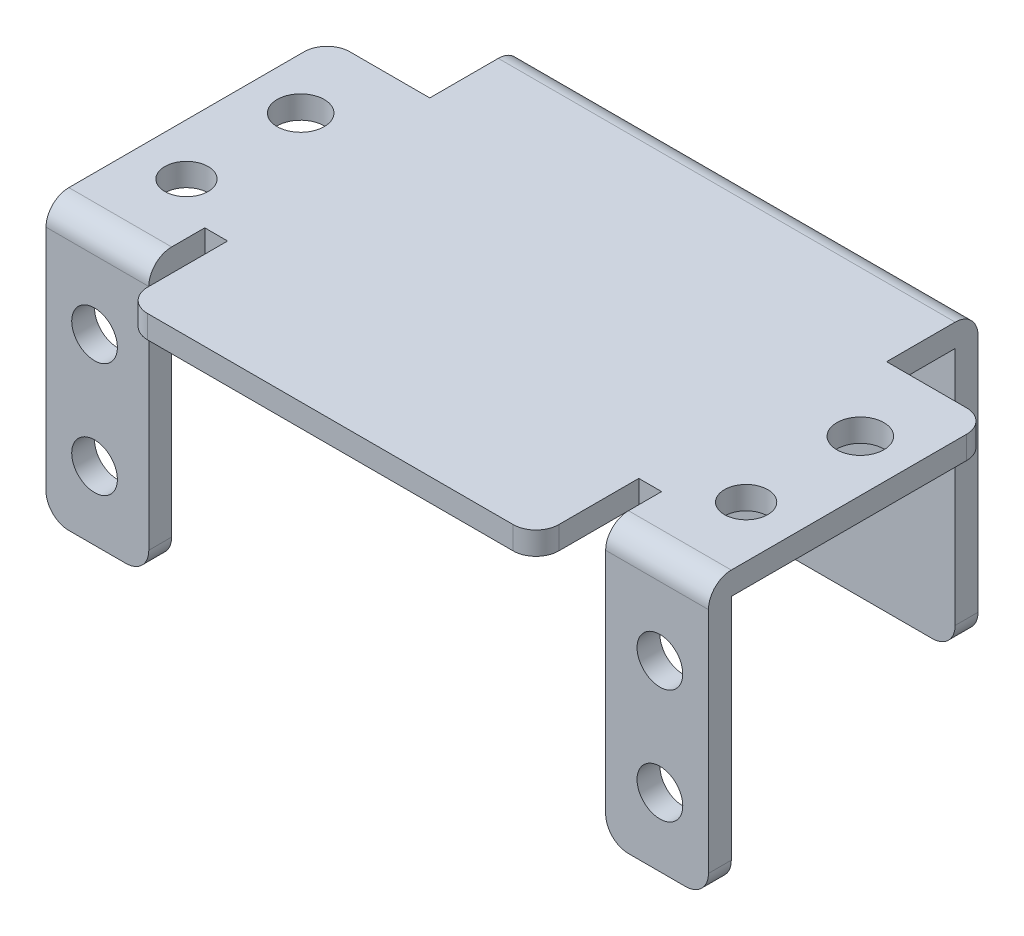
from build123d import *

# Parameters (mm, degrees)
SKETCH_1_W            = 32.6
SKETCH_1_H            = 23.999999657
EXTRUDE_1_DEPTH       = 8.999999702
SKETCH_2_W            = 30.6
SKETCH_2_H            = 22
CUT_EXTRUDE_1_DEPTH   = 9.999999702
SKETCH_3_W            = 27.7
SKETCH_3_H            = 1.999999657
EXTRUDE_2_DEPTH       = 49.000000298
SKETCH_4_W            = 8.999999702
SKETCH_4_H            = 1.999999657
EXTRUDE_3_DEPTH       = 4.9
SKETCH_5_W            = 8.999999702
SKETCH_5_H            = 2
EXTRUDE_4_DEPTH       = 22
SKETCH_6_W            = 9
SKETCH_6_H            = 8
CUT_EXTRUDE_2_DEPTH   = 24.999999657
SKETCH_7_W            = 9
SKETCH_7_H            = 8
CUT_EXTRUDE_3_DEPTH   = 24.999999657
SKETCH_8_W            = 40
SKETCH_8_H            = 2
EXTRUDE_5_DEPTH       = 23.000000343
SKETCH_9_W            = 36.000000596
SKETCH_9_H            = 1.999999657
EXTRUDE_6_DEPTH       = 9
HOLE_WIZARD_4_0_4_1_D = 4
FILLET_1_R            = 2
SKETCH_12_R           = 1.897672249
SKETCH_12_R_2         = 2.0621459
CUT_EXTRUDE_4_DEPTH   = 2.999999657


with BuildPart() as part:
    # 草图1 → 凸台-拉伸1 (new body)
    with BuildSketch(Plane(origin=(29, 0, 0), x_dir=(0, 0, -1), z_dir=(1, 0, 0))):
        with Locations((-16.3, 13.000000171)):
            Rectangle(SKETCH_1_W, SKETCH_1_H)
    extrude(amount=-EXTRUDE_1_DEPTH)

    # 草图2 → 切除-拉伸1 (cut, through all)
    with BuildSketch(Plane.ZY.offset(-20.000000298)):
        with Locations((15.3, 12.000000343)):
            Rectangle(SKETCH_2_W, SKETCH_2_H)
    extrude(amount=-CUT_EXTRUDE_1_DEPTH, mode=Mode.SUBTRACT)

    # 草图3 → 凸台-拉伸2 (add)
    with BuildSketch(Plane.ZY.offset(-20.000000298)):
        with Locations((13.85, 24.000000171)):
            Rectangle(SKETCH_3_W, SKETCH_3_H)
    extrude(amount=EXTRUDE_2_DEPTH)

    # 草图4 → 凸台-拉伸3 (add)
    with BuildSketch(Plane.XY.offset(27.7)):
        with Locations((-24.500000149, 24.000000171)):
            Rectangle(SKETCH_4_W, SKETCH_4_H)
    extrude(amount=EXTRUDE_3_DEPTH)

    # 草图5 → 凸台-拉伸4 (add)
    with BuildSketch(Plane.XZ.offset(-23.000000343)):
        with Locations((-24.500000149, 31.6)):
            Rectangle(SKETCH_5_W, SKETCH_5_H)
    extrude(amount=EXTRUDE_4_DEPTH)

    # 草图6 → 切除-拉伸2 (cut, through all)
    with BuildSketch(Plane(origin=(0, 25, 0), x_dir=(-1, 0, 0), z_dir=(0, 1, 0))):
        with Locations((24.5, 4)):
            Rectangle(SKETCH_6_W, SKETCH_6_H)
    extrude(amount=-CUT_EXTRUDE_2_DEPTH, mode=Mode.SUBTRACT)

    # 草图7 → 切除-拉伸3 (cut, through all)
    with BuildSketch(Plane(origin=(0, 25, 0), x_dir=(-1, 0, 0), z_dir=(0, 1, 0))):
        with Locations((-24.5, 4)):
            Rectangle(SKETCH_7_W, SKETCH_7_H)
    extrude(amount=-CUT_EXTRUDE_3_DEPTH, mode=Mode.SUBTRACT)

    # 草图8 → 凸台-拉伸5 (add)
    with BuildSketch(Plane.XZ.offset(-23.000000343)):
        with Locations((0, 1)):
            Rectangle(SKETCH_8_W, SKETCH_8_H)
    extrude(amount=EXTRUDE_5_DEPTH)

    # 草图9 → 凸台-拉伸6 (add)
    with BuildSketch(Plane.XY.offset(27.7)):
        with Locations((0, 24.000000171)):
            Rectangle(SKETCH_9_W, SKETCH_9_H)
    extrude(amount=EXTRUDE_6_DEPTH)

    # Ø4.0 (4) 直径孔1 (through all)
    with Locations(Plane(origin=(0, 0, 30.6), x_dir=(-1, 0, 0), z_dir=(0, 0, -1))):
        with Locations((-24.75, 17.000000343), (-24.75, 7.000000343), (24.75, 17.000000343), (24.75, 7.000000343)):
            Hole(HOLE_WIZARD_4_0_4_1_D / 2)

    # 圆角1
    fillet_1_edges = [part.edges().sort_by_distance(p)[0] for p in [
        (-20, 0, 1),
        (20, 0, 1),
        (-18.000000298, 24.000000171, 36.7),
        (18.000000298, 24.000000171, 36.7),
        (-24.500000149, 25, 32.6),
        (-20.000000298, 1.000000343, 31.6),
        (-29, 1.000000343, 31.6),
        (29, 1.000000343, 31.6),
        (-29, 24.000000171, 8),
        (0, 25, 0),
        (24.500000149, 25, 32.6),
        (20.000000298, 1.000000343, 31.6),
        (29, 24.000000171, 8),
    ]]
    fillet(fillet_1_edges, radius=FILLET_1_R)

    # 草图12 → 切除-拉伸4 (cut, through all)
    with BuildSketch(Plane.XZ.offset(-23.000000343)):
        with Locations((-24.500000149, 24.8)):
            Circle(SKETCH_12_R)
        with Locations((-24.500000149, 14.8)):
            Circle(SKETCH_12_R_2)
        with Locations((24.500000149, 14.8)):
            Circle(SKETCH_12_R_2)
        with Locations((24.500000149, 24.8)):
            Circle(SKETCH_12_R)
    extrude(amount=-CUT_EXTRUDE_4_DEPTH, mode=Mode.SUBTRACT)


solid = part.part
